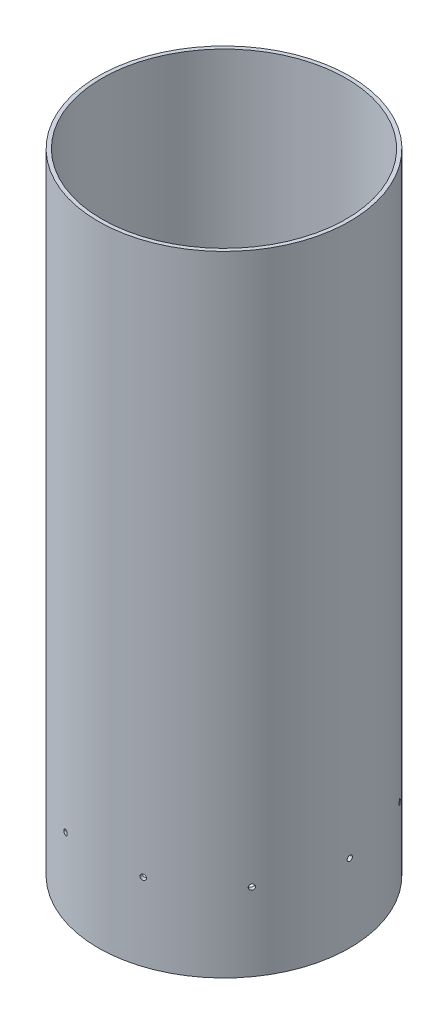
from build123d import *

# Parameters (mm, degrees)
SKETCH2_R                       = 76.1746
SKETCH2_R_2                     = 73.914
BOSS_EXTRUDE1_DEPTH             = 381
F_1_8_0_1250_DOWEL_HOLE1_REACH  = 419.341
F_1_8_0_1250_DOWEL_HOLE1_BORE_R = 1.5875
CIRPATTERN1_COUNT               = 10


with BuildPart() as part:
    # Sketch2 → Boss-Extrude1 (new body)
    with BuildSketch(Plane(origin=(0, 0, 0), x_dir=(1, 0, 0), z_dir=(0, 1, 0))):
        with Locations(Location((0, 0, 0), (0, 0, 270))):
            Circle(SKETCH2_R)
        with Locations(Location((0, 0, 0), (0, 0, 270))):
            Circle(SKETCH2_R_2, mode=Mode.SUBTRACT)
    extrude(amount=BOSS_EXTRUDE1_DEPTH)

    # 1/8 (0.1250) Dowel Hole1 bore → 1/8 (0.1250) Dowel Hole1 (cut, up to next)
    with BuildSketch(Plane(origin=(76.1746, 0, 0), x_dir=(0, 0, -1), z_dir=(1, 0, 0)), mode=Mode.PRIVATE) as f_1_8_0_1250_dowel_hole1_sk1:
        with Locations((0, 46.99)):
            Circle(F_1_8_0_1250_DOWEL_HOLE1_BORE_R)
    f_1_8_0_1250_dowel_hole1_tool1 = extrude(f_1_8_0_1250_dowel_hole1_sk1.sketch, amount=-F_1_8_0_1250_DOWEL_HOLE1_REACH, mode=Mode.PRIVATE) & part.part
    f_1_8_0_1250_dowel_hole1 = f_1_8_0_1250_dowel_hole1_tool1.solids().sort_by_distance((76.1746, 46.99, 0))[0]
    add(f_1_8_0_1250_dowel_hole1, mode=Mode.SUBTRACT)

    # CirPattern1: 1/8 (0.1250) Dowel Hole1 ×10 about axis
    cirpattern1_axis = Axis((0, 381, 0), (0, -1, 0))
    for i in range(1, CIRPATTERN1_COUNT):
        add(f_1_8_0_1250_dowel_hole1.rotate(cirpattern1_axis, i * 360 / CIRPATTERN1_COUNT), mode=Mode.SUBTRACT)


solid = part.part
